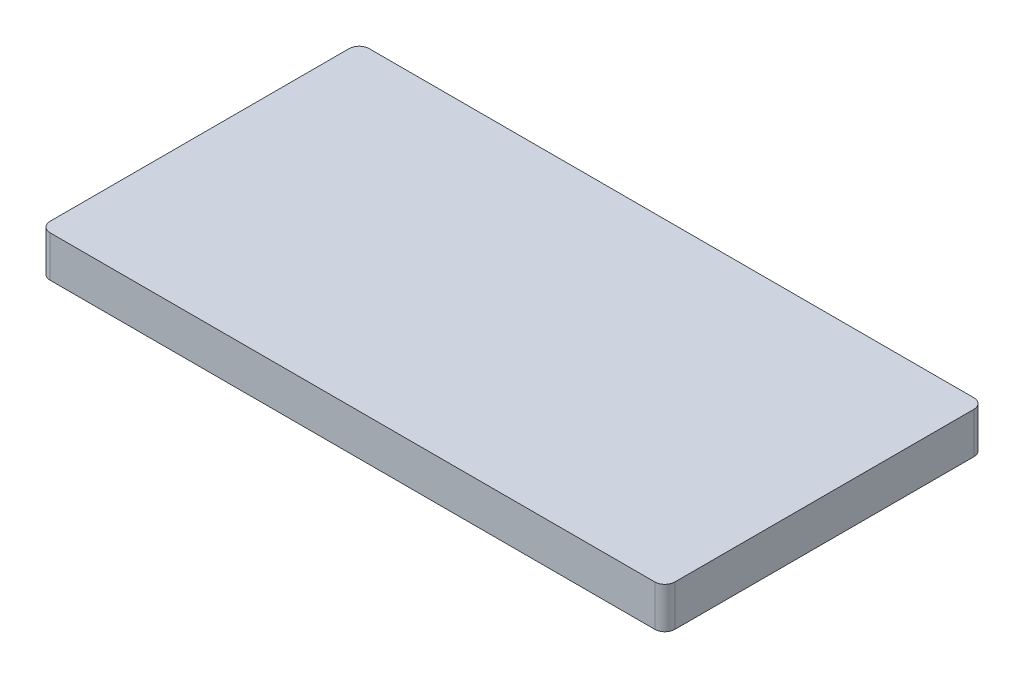
from build123d import *

# Parameters (mm, degrees)
SKETCH1_W           = 124.65
SKETCH1_H           = 63.65
BOSS_EXTRUDE1_DEPTH = 8.2
SKETCH2_W           = 7.72
SKETCH2_H           = 2.7
SKETCH2_W_2         = 12.3
SKETCH2_H_2         = 5.3
CUT_EXTRUDE1_DEPTH  = 12
SKETCH3_W           = 1
SKETCH3_H           = 9
CUT_EXTRUDE2_DEPTH  = 1
FILLET1_R           = 2


with BuildPart() as part:
    # Sketch1 → Boss-Extrude1 (new body)
    with BuildSketch(Plane(origin=(0, 0, 0), x_dir=(1, 0, 0), z_dir=(0, 1, 0))):
        with Locations((4.430687204, 1.109774882)):
            Rectangle(SKETCH1_W, SKETCH1_H)
    extrude(amount=BOSS_EXTRUDE1_DEPTH)

    # Sketch2 → Cut-Extrude1 (cut)
    with BuildSketch(Plane.ZY.offset(57.894312796)):
        with Locations((-1.109774882, 4.1)):
            Rectangle(SKETCH2_W, SKETCH2_H)
        with Locations((18.220036332, 4.1)):
            Rectangle(SKETCH2_W_2, SKETCH2_H_2)
    extrude(amount=-CUT_EXTRUDE1_DEPTH, mode=Mode.SUBTRACT)

    # Sketch3 → Cut-Extrude2 (cut)
    with BuildSketch(Plane.XZ):
        with Locations((-46.194312796, -19.434774882)):
            Rectangle(SKETCH3_W, SKETCH3_H)
    extrude(amount=-CUT_EXTRUDE2_DEPTH, mode=Mode.SUBTRACT)

    # Fillet1
    fillet1_edges = [part.edges().sort_by_distance(p)[0] for p in [
        (-57.894312796, 4.1, -32.934774882),
        (66.755687204, 4.1, -32.934774882),
        (66.755687204, 4.1, 30.715225118),
        (-57.894312796, 4.1, 30.715225118),
    ]]
    fillet(fillet1_edges, radius=FILLET1_R)


solid = part.part
